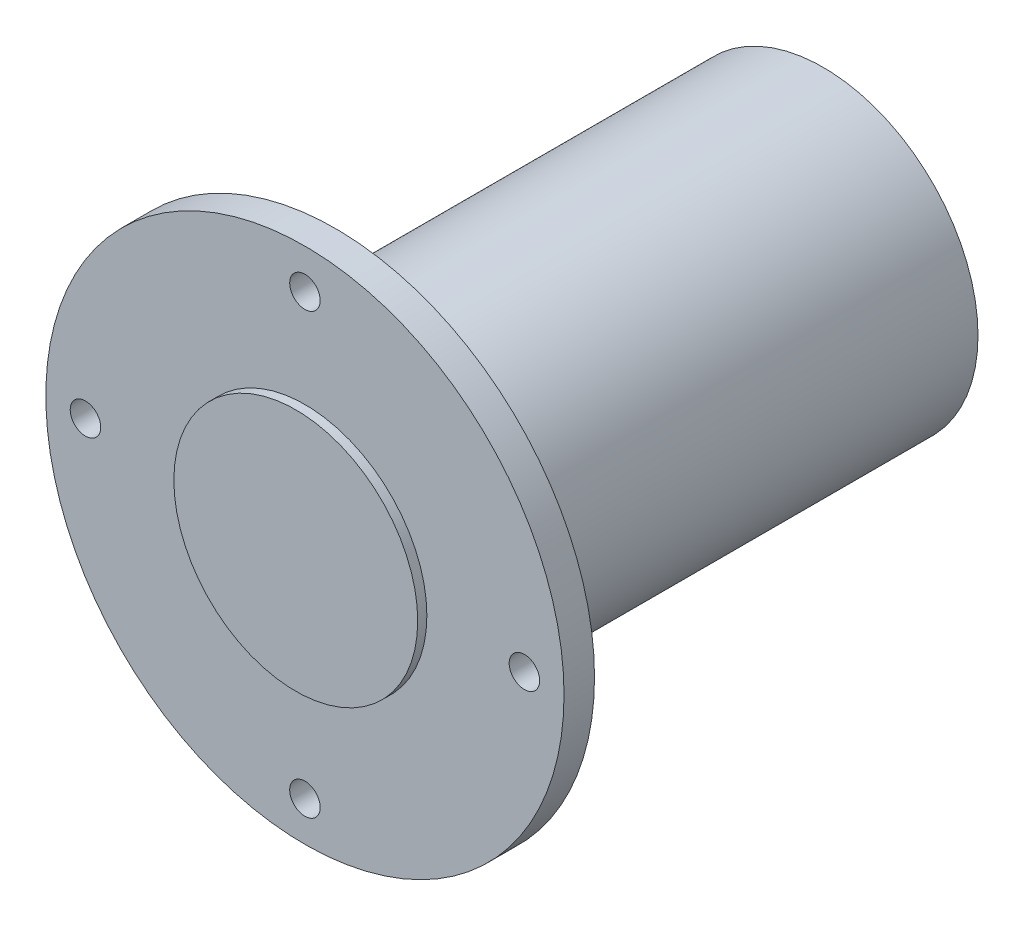
from build123d import *

# Parameters (mm, degrees)
SKETCH1_R                 = 42.5
BOSS_EXTRUDE1_DEPTH       = 5
SKETCH4_R                 = 25.4
BOSS_EXTRUDE2_DEPTH       = 80
SKETCH5_R                 = 20.4
CUT_EXTRUDE1_DEPTH        = 70
FILLET1_R                 = 5
M6X1_0_TAPPED_HOLE1_D     = 5
M6X1_0_TAPPED_HOLE1_DEPTH = 5
SKETCH8_R                 = 20
BOSS_EXTRUDE3_DEPTH       = 1.5


with BuildPart() as part:
    # Sketch1 → Boss-Extrude1 (new body)
    with BuildSketch(Plane.XY):
        Circle(SKETCH1_R)
    extrude(amount=BOSS_EXTRUDE1_DEPTH)

    # Sketch4 → Boss-Extrude2 (add)
    with BuildSketch(Plane(origin=(0, 0, 0), x_dir=(-1, 0, 0), z_dir=(0, 0, -1))):
        Circle(SKETCH4_R)
    extrude(amount=BOSS_EXTRUDE2_DEPTH)

    # Sketch5 → Cut-Extrude1 (cut)
    with BuildSketch(Plane(origin=(0, 0, -80), x_dir=(-1, 0, 0), z_dir=(0, 0, -1))):
        Circle(SKETCH5_R)
    extrude(amount=-CUT_EXTRUDE1_DEPTH, mode=Mode.SUBTRACT)

    # Fillet1
    fillet1_edges = [part.edges().sort_by_distance(p)[0] for p in [
        (25.4, 0, 0),
    ]]
    fillet(fillet1_edges, radius=FILLET1_R)

    # M6x1.0 Tapped Hole1
    with Locations(Plane(origin=(0, 0, 0), x_dir=(-1, 0, 0), z_dir=(0, 0, -1))):
        with Locations((0, 36), (36, 0), (0, -36), (-36, 0)):
            Hole(M6X1_0_TAPPED_HOLE1_D / 2, depth=M6X1_0_TAPPED_HOLE1_DEPTH)

    # Sketch8 → Boss-Extrude3 (add)
    with BuildSketch(Plane.XY.offset(5)):
        Circle(SKETCH8_R)
    extrude(amount=BOSS_EXTRUDE3_DEPTH)


solid = part.part
